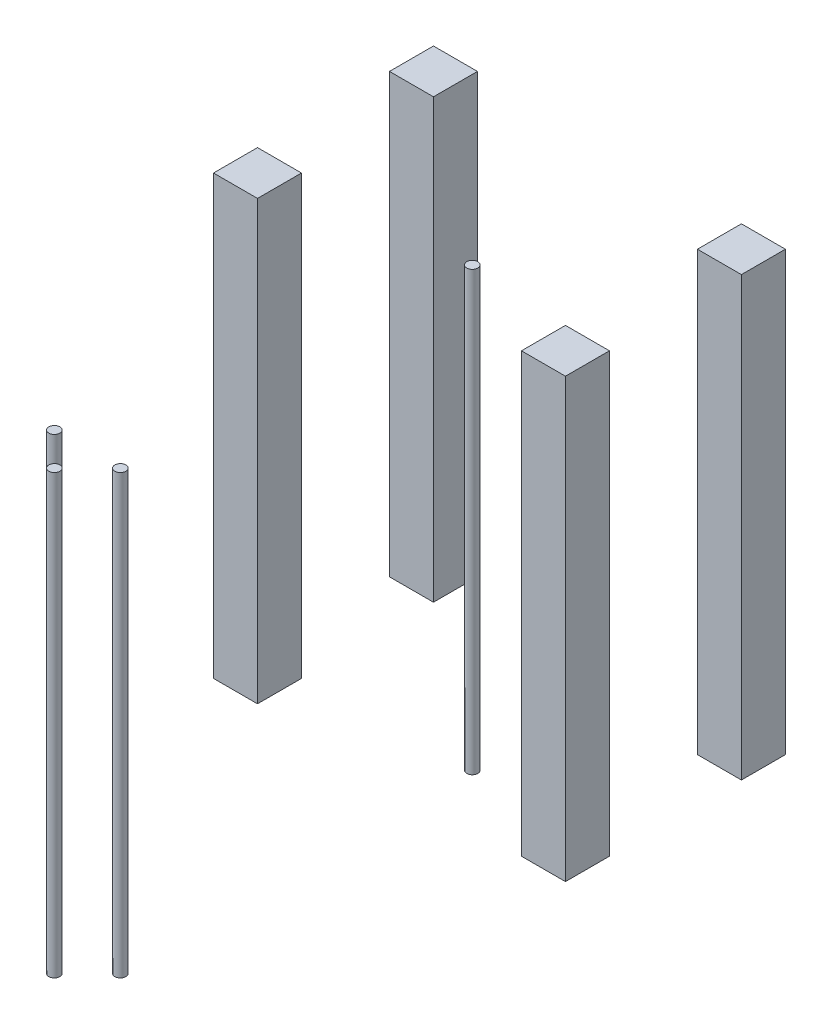
from build123d import *

# Parameters (mm, degrees)
SKIZZE3_R                         = 2.5
AUFSATZ_LINEAR_AUSTRAGEN1_DEPTH   = 199
AUFSATZ_LINEAR_AUSTRAGEN1_2_DEPTH = 199
AUFSATZ_LINEAR_AUSTRAGEN1_3_DEPTH = 199
AUFSATZ_LINEAR_AUSTRAGEN1_4_DEPTH = 199
SKIZZE3_W                         = 20
SKIZZE3_H                         = 20
AUFSATZ_LINEAR_AUSTRAGEN1_5_DEPTH = 199
AUFSATZ_LINEAR_AUSTRAGEN1_6_DEPTH = 199
AUFSATZ_LINEAR_AUSTRAGEN1_7_DEPTH = 199
AUFSATZ_LINEAR_AUSTRAGEN1_8_DEPTH = 199


with BuildPart() as part:
    # Skizze3 → Aufsatz-Linear austragen1 (new body)
    with BuildSketch(Plane(origin=(0, 0, 0), x_dir=(1, 0, 0), z_dir=(0, 1, 0))):
        with Locations((15, -110)):
            Circle(SKIZZE3_R)
    extrude(amount=AUFSATZ_LINEAR_AUSTRAGEN1_DEPTH)


with BuildPart() as body_2:
    # Skizze3 → Aufsatz-Linear austragen1 2 (new body)
    with BuildSketch(Plane(origin=(0, 0, 0), x_dir=(1, 0, 0), z_dir=(0, 1, 0))):
        with Locations((-15, -270)):
            Circle(SKIZZE3_R)
    extrude(amount=AUFSATZ_LINEAR_AUSTRAGEN1_2_DEPTH)


with BuildPart() as body_3:
    # Skizze3 → Aufsatz-Linear austragen1 3 (new body)
    with BuildSketch(Plane(origin=(0, 0, 0), x_dir=(1, 0, 0), z_dir=(0, 1, 0))):
        with Locations((0, -285)):
            Circle(SKIZZE3_R)
    extrude(amount=AUFSATZ_LINEAR_AUSTRAGEN1_3_DEPTH)


with BuildPart() as body_4:
    # Skizze3 → Aufsatz-Linear austragen1 4 (new body)
    with BuildSketch(Plane(origin=(0, 0, 0), x_dir=(1, 0, 0), z_dir=(0, 1, 0))):
        with Locations((15, -270)):
            Circle(SKIZZE3_R)
    extrude(amount=AUFSATZ_LINEAR_AUSTRAGEN1_4_DEPTH)


with BuildPart() as body_5:
    # Skizze3 → Aufsatz-Linear austragen1 5 (new body)
    with BuildSketch(Plane(origin=(0, 0, 0), x_dir=(1, 0, 0), z_dir=(0, 1, 0))):
        with Locations((-70, -42.65)):
            Rectangle(SKIZZE3_W, SKIZZE3_H)
    extrude(amount=AUFSATZ_LINEAR_AUSTRAGEN1_5_DEPTH)


with BuildPart() as body_6:
    # Skizze3 → Aufsatz-Linear austragen1 6 (new body)
    with BuildSketch(Plane(origin=(0, 0, 0), x_dir=(1, 0, 0), z_dir=(0, 1, 0))):
        with Locations((70, -42.65)):
            Rectangle(SKIZZE3_W, SKIZZE3_H)
    extrude(amount=AUFSATZ_LINEAR_AUSTRAGEN1_6_DEPTH)


with BuildPart() as body_7:
    # Skizze3 → Aufsatz-Linear austragen1 7 (new body)
    with BuildSketch(Plane(origin=(0, 0, 0), x_dir=(1, 0, 0), z_dir=(0, 1, 0))):
        with Locations((70, -122.65)):
            Rectangle(SKIZZE3_W, SKIZZE3_H)
    extrude(amount=AUFSATZ_LINEAR_AUSTRAGEN1_7_DEPTH)


with BuildPart() as body_8:
    # Skizze3 → Aufsatz-Linear austragen1 8 (new body)
    with BuildSketch(Plane(origin=(0, 0, 0), x_dir=(1, 0, 0), z_dir=(0, 1, 0))):
        with Locations((-70, -122.65)):
            Rectangle(SKIZZE3_W, SKIZZE3_H)
    extrude(amount=AUFSATZ_LINEAR_AUSTRAGEN1_8_DEPTH)


solid = Compound([part.part, body_2.part, body_3.part, body_4.part, body_5.part, body_6.part, body_7.part, body_8.part])
